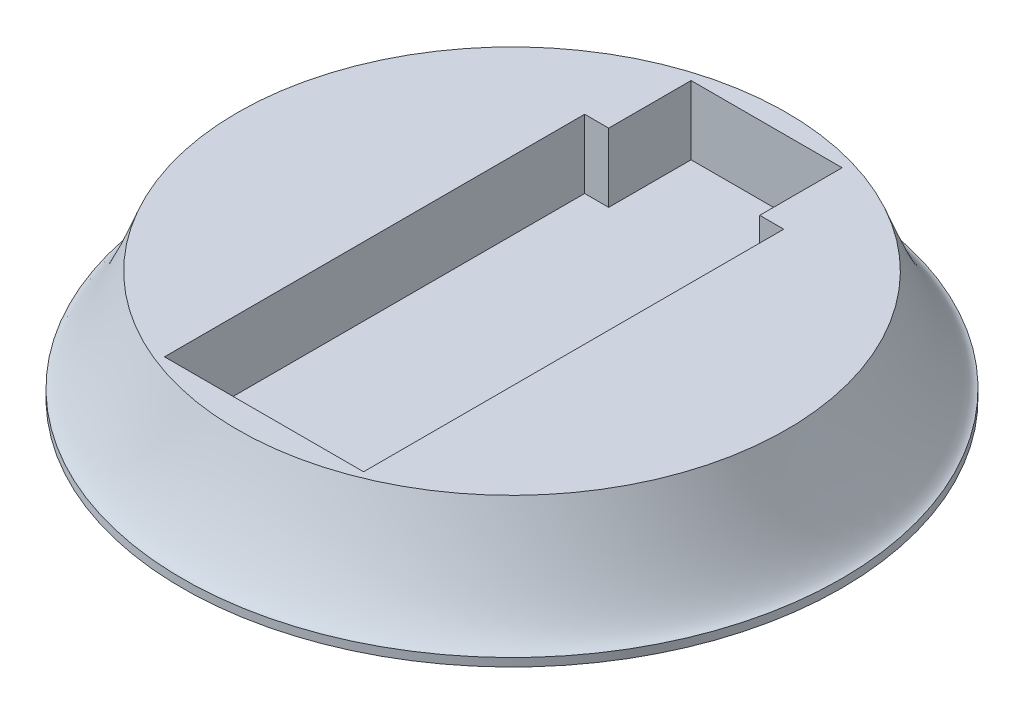
from build123d import *

# Parameters (mm, degrees)
CUT_EXTRUDE_1_DEPTH = 25


with BuildPart() as part:
    # 草图1 → 旋转2 (revolve)
    with BuildSketch(Plane.XY, mode=Mode.PRIVATE) as revolve_2_sk:
        with BuildLine():
            Line((0, 0), (120, 0))
            Line((120, 0), (120, 3))
            add(Edge.make_bspline(
                [(100, 40), (113.464773616, 4.300155843), (120, 3)],
                knots=[0, 0, 0, 0.922507556, 0.922507556, 0.922507556], degree=2))
            Line((100, 40), (0, 40))
            Line((0, 40), (0, 0))
        make_face()
    revolve(revolve_2_sk.sketch.rotate(Axis((0, 40, 0), (0, -1, 0)), 180), axis=Axis((0, 40, 0), (0, -1, 0)))  # turned: the seam where the file's is

    # 草图2 → 切除-拉伸1 (cut)
    with BuildSketch(Plane(origin=(0, 40, 0), x_dir=(1, 0, 0), z_dir=(0, 1, 0))):
        Polygon((36.25, -90.290489125), (-36.25, -90.290489125), (-36.25, 62.709510875), (-27.5, 62.709510875), (-27.5, 92.709510875), (27.5, 92.709510875), (27.5, 62.709510875), (36.25, 62.709510875), align=None)
    extrude(amount=-CUT_EXTRUDE_1_DEPTH, mode=Mode.SUBTRACT)


solid = part.part
